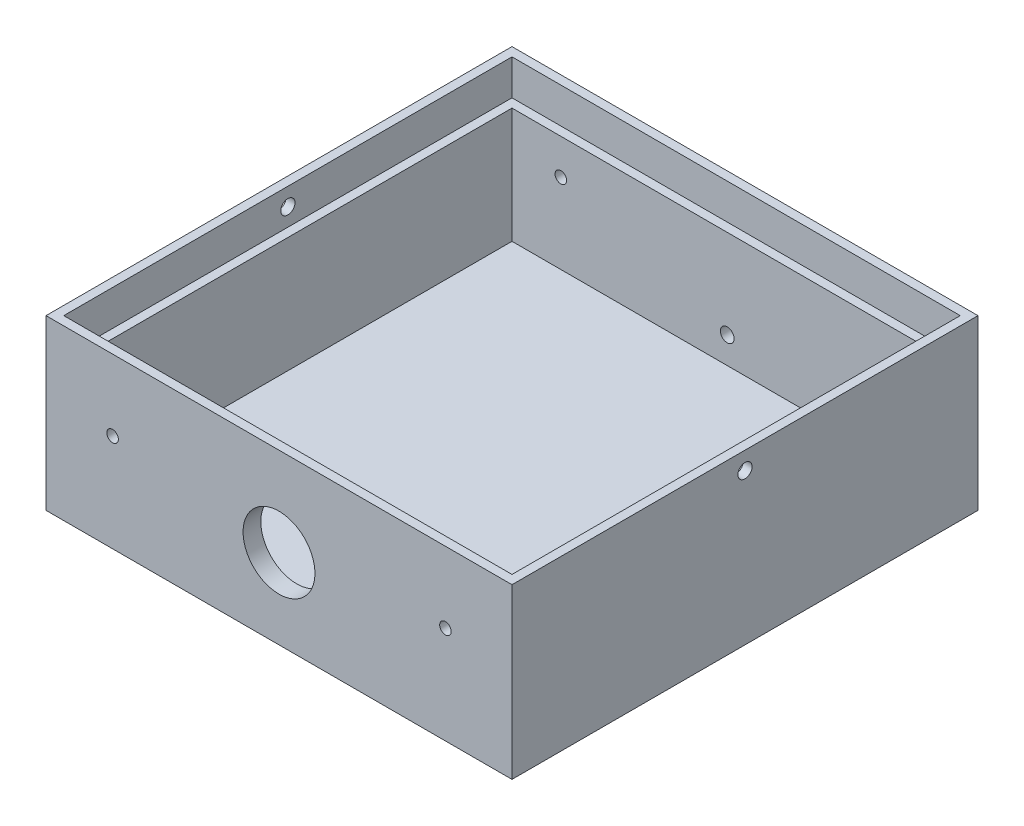
from build123d import *

# Parameters (mm, degrees)
SKETCH1_W           = 105
SKETCH1_H           = 105
BOSS_EXTRUDE1_DEPTH = 38
SKETCH2_W           = 97
SKETCH2_H           = 97
CUT_EXTRUDE1_DEPTH  = 34
SKETCH3_W           = 101
SKETCH3_H           = 101
CUT_EXTRUDE2_DEPTH  = 8
SKETCH5_R           = 1.6
CUT_EXTRUDE3_DEPTH  = 106
CUT_EXTRUDE4_REACH  = 6
SKETCH7_R           = 8.1
CUT_EXTRUDE5_DEPTH  = 1
SKETCH11_R          = 1.3
CUT_EXTRUDE6_DEPTH  = 106
CUT_EXTRUDE7_REACH  = 107
SKETCH12_R          = 1.55


with BuildPart() as part:
    # Sketch1 → Boss-Extrude1 (new body)
    with BuildSketch(Plane(origin=(0, 0, 0), x_dir=(1, 0, 0), z_dir=(0, 1, 0))):
        Rectangle(SKETCH1_W, SKETCH1_H)
    extrude(amount=BOSS_EXTRUDE1_DEPTH)

    # Sketch2 → Cut-Extrude1 (cut)
    with BuildSketch(Plane(origin=(0, 38, 0), x_dir=(1, 0, 0), z_dir=(0, 1, 0))):
        Rectangle(SKETCH2_W, SKETCH2_H)
    extrude(amount=-CUT_EXTRUDE1_DEPTH, mode=Mode.SUBTRACT)

    # Sketch3 → Cut-Extrude2 (cut)
    with BuildSketch(Plane(origin=(0, 38, 0), x_dir=(1, 0, 0), z_dir=(0, 1, 0))):
        Rectangle(SKETCH3_W, SKETCH3_H)
    extrude(amount=-CUT_EXTRUDE2_DEPTH, mode=Mode.SUBTRACT)

    # Sketch5 → Cut-Extrude3 (cut, through all)
    with BuildSketch(Plane(origin=(52.5, 0, 0), x_dir=(0, 0, -1), z_dir=(1, 0, 0))):
        with Locations((0, 34)):
            Circle(SKETCH5_R)
    extrude(amount=-CUT_EXTRUDE3_DEPTH, mode=Mode.SUBTRACT)

    # Sketch7 → Cut-Extrude4 (cut, up to next)
    with BuildSketch(Plane(origin=(0, 0, 48.5), x_dir=(-1, 0, 0), z_dir=(0, 0, -1)), mode=Mode.PRIVATE) as cut_extrude4_sk1:
        with Locations((0, 18)):
            Circle(SKETCH7_R)
    cut_extrude4_tool1 = extrude(cut_extrude4_sk1.sketch, amount=-CUT_EXTRUDE4_REACH, mode=Mode.PRIVATE) & part.part
    add(cut_extrude4_tool1.solids().sort_by_distance((0, 18, 48.5))[0], mode=Mode.SUBTRACT)

    # Sketch10 → Cut-Extrude5 (cut)
    with BuildSketch(Plane.XZ):
        with BuildLine():
            Line((5, -10), (0, -10))
            ThreePointArc((0, -10), (-5, -5), (0, 0))
            ThreePointArc((0, 0), (-5, 5), (0, 10))
            Line((0, 10), (5, 10))
            Line((5, 10), (5, -10))
        make_face()
        with BuildLine():
            Line((0, -7), (2, -7))
            Line((2, -7), (2, -3))
            Line((2, -3), (0, -3))
            ThreePointArc((0, -3), (-2, -5), (0, -7))
        make_face(mode=Mode.SUBTRACT)
        with BuildLine():
            Line((0, 3), (2, 3))
            Line((2, 3), (2, 7))
            Line((2, 7), (0, 7))
            ThreePointArc((0, 7), (-2, 5), (0, 3))
        make_face(mode=Mode.SUBTRACT)
    extrude(amount=-CUT_EXTRUDE5_DEPTH, mode=Mode.SUBTRACT)

    # Sketch11 → Cut-Extrude6 (cut, through all)
    with BuildSketch(Plane.XY.offset(52.5)):
        with Locations((-37.5, 22)):
            Circle(SKETCH11_R)
        with Locations((37.5, 22)):
            Circle(SKETCH11_R)
    extrude(amount=-CUT_EXTRUDE6_DEPTH, mode=Mode.SUBTRACT)

    # Sketch12 → Cut-Extrude7 (cut, up to next)
    with BuildSketch(Plane(origin=(0, 0, -52.5), x_dir=(-1, 0, 0), z_dir=(0, 0, -1)), mode=Mode.PRIVATE) as cut_extrude7_sk1:
        with Locations((0, 10)):
            Circle(SKETCH12_R)
    cut_extrude7_tool1 = extrude(cut_extrude7_sk1.sketch, amount=-CUT_EXTRUDE7_REACH, mode=Mode.PRIVATE) & part.part
    add(cut_extrude7_tool1.solids().sort_by_distance((0, 10, -52.5))[0], mode=Mode.SUBTRACT)


solid = part.part
